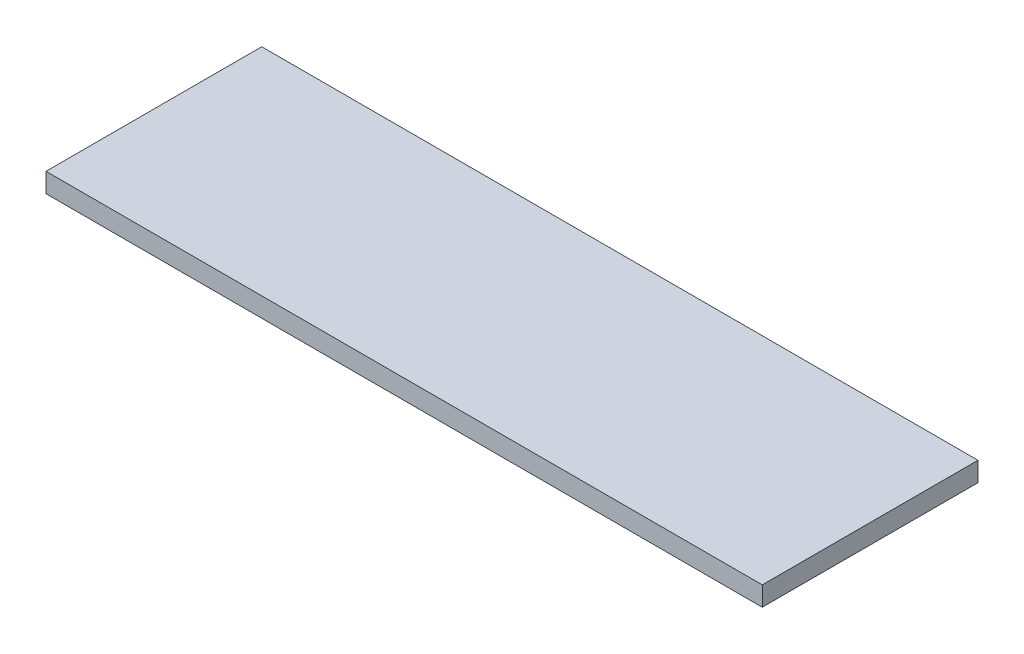
from build123d import *

# Parameters (mm, degrees)
SKETCH_1_W      = 66.4
SKETCH_1_H      = 20
EXTRUDE_1_DEPTH = 1.8


with BuildPart() as part:
    # 草图1 → 凸台-拉伸1 (new body)
    with BuildSketch(Plane(origin=(0, 0, 0), x_dir=(1, 0, 0), z_dir=(0, 1, 0))):
        with Locations((33.2, 10)):
            Rectangle(SKETCH_1_W, SKETCH_1_H)
    extrude(amount=EXTRUDE_1_DEPTH)


solid = part.part
